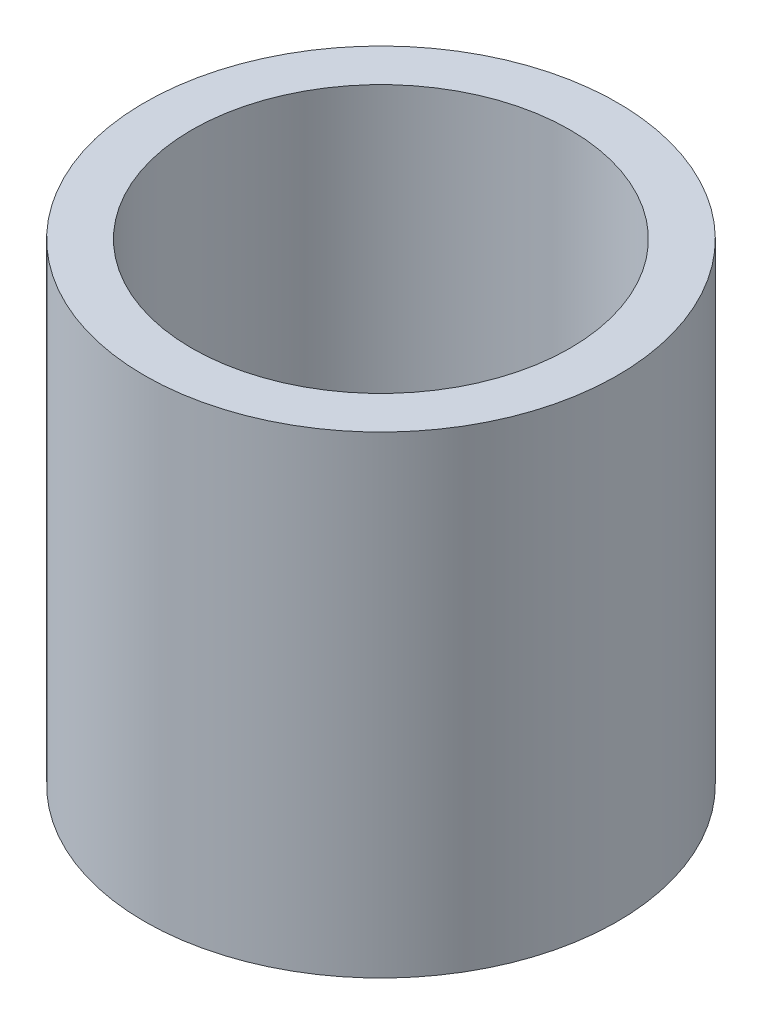
from build123d import *

# Parameters (mm, degrees)
SKETCH1_R           = 6.35
BOSS_EXTRUDE1_DEPTH = 12.7
SKETCH2_R           = 5.08
CUT_EXTRUDE1_DEPTH  = 13.716


with BuildPart() as part:
    # Sketch1 → Boss-Extrude1 (new body)
    with BuildSketch(Plane(origin=(0, 0, 0), x_dir=(1, 0, 0), z_dir=(0, 1, 0))):
        with Locations((-4.059276624, 2.553415941)):
            Circle(SKETCH1_R)
    extrude(amount=BOSS_EXTRUDE1_DEPTH)

    # Sketch2 → Cut-Extrude1 (cut)
    with BuildSketch(Plane(origin=(0, 12.7, 0), x_dir=(1, 0, 0), z_dir=(0, 1, 0))):
        with Locations((-4.059276624, 2.553415941)):
            Circle(SKETCH2_R)
    extrude(amount=-CUT_EXTRUDE1_DEPTH, mode=Mode.SUBTRACT)


solid = part.part
